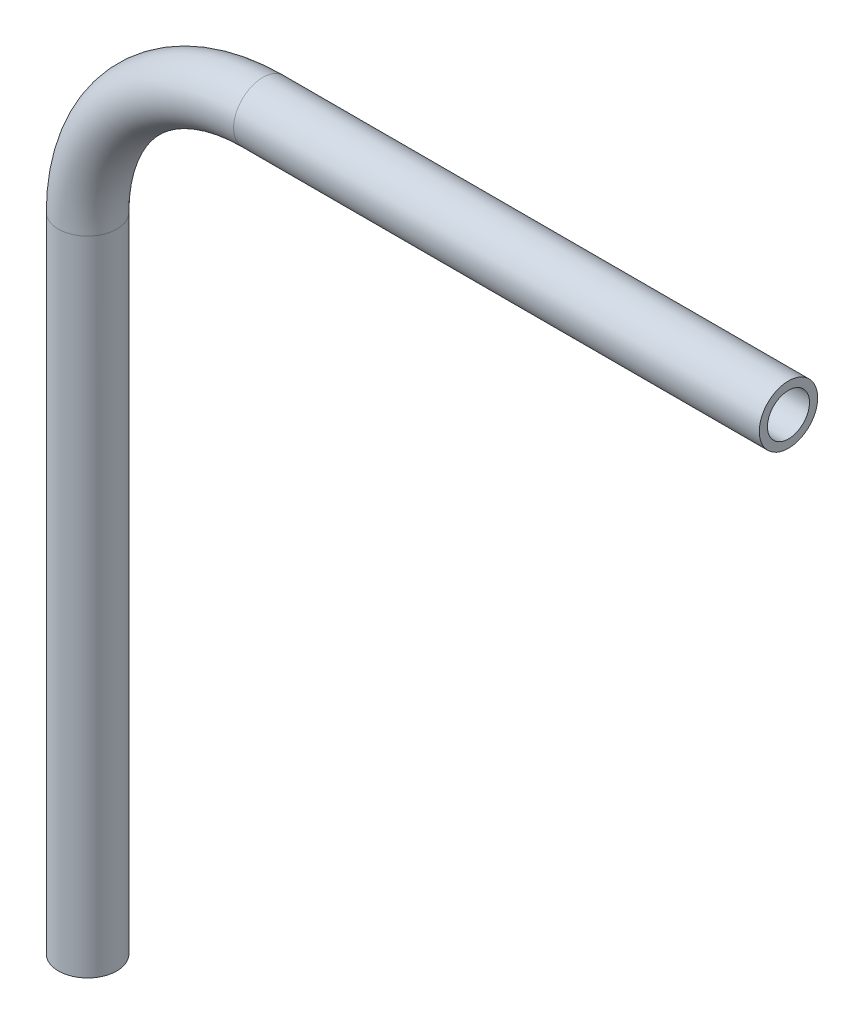
from build123d import *

# Parameters (mm, degrees)
SKETCH2_R   = 3.175
SKETCH2_R_2 = 2.286


with BuildPart() as part:
    # Sweep1: sweep along a path in Sketch1
    with BuildLine(Plane.XY) as sweep1_path:
        Line((0, -71.372317881), (0, -1.522317881))
        ThreePointArc((0, -1.522317881), (5.579615818, 11.948066301), (19.05, 17.527682119))
        Line((19.05, 17.527682119), (76.2, 17.527682119))
    # Sketch2 → Sweep1 (sweep)
    with BuildSketch(Plane(origin=(76.2, 17.527682119, 0), x_dir=(0, 0, -1), z_dir=(1, 0, 0))):
        Circle(SKETCH2_R)
        Circle(SKETCH2_R_2, mode=Mode.SUBTRACT)
    sweep(path=sweep1_path.line)


solid = part.part
